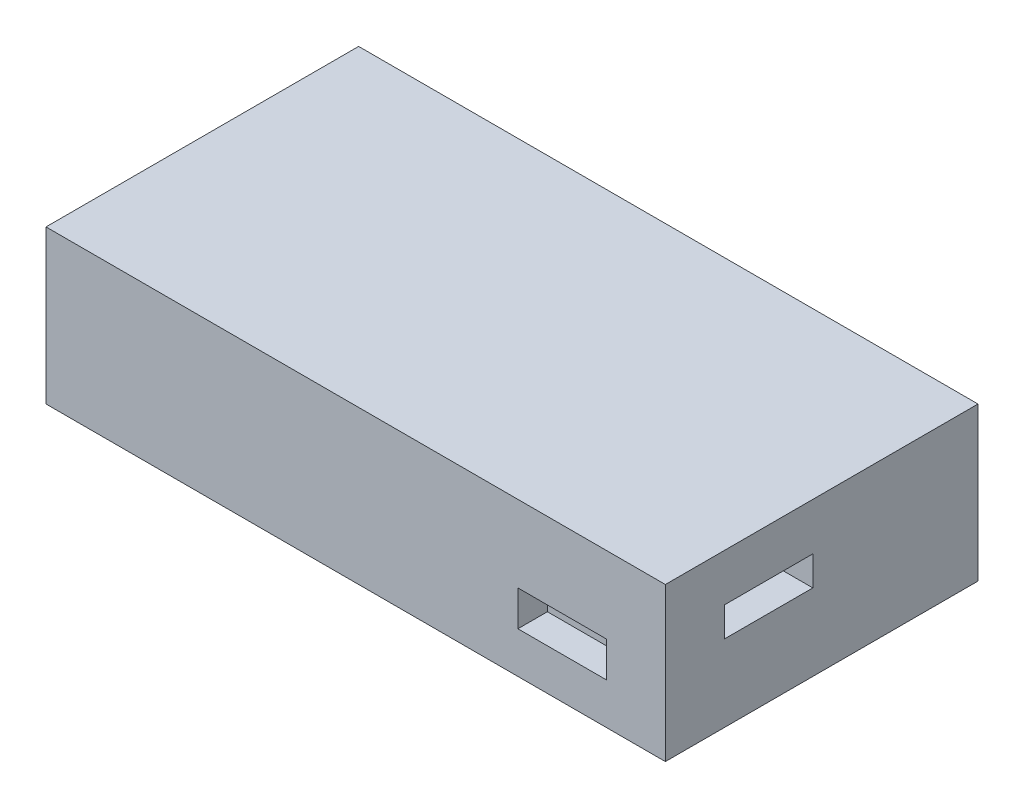
from build123d import *

# Parameters (mm, degrees)
SKETCH2_W           = 105
SKETCH2_H           = 53
BOSS_EXTRUDE1_DEPTH = 26
SKETCH3_W           = 15
SKETCH3_H           = 6
CUT_EXTRUDE1_DEPTH  = 5
SKETCH4_W           = 15
SKETCH4_H           = 5
CUT_EXTRUDE2_DEPTH  = 10


with BuildPart() as part:
    # Sketch2 → Boss-Extrude1 (new body)
    with BuildSketch(Plane(origin=(0, 0, 0), x_dir=(1, 0, 0), z_dir=(0, 1, 0))):
        with Locations((52.5, 26.5)):
            Rectangle(SKETCH2_W, SKETCH2_H)
    extrude(amount=BOSS_EXTRUDE1_DEPTH)

    # Sketch3 → Cut-Extrude1 (cut)
    with BuildSketch(Plane.XY):
        with Locations((87.5, 10)):
            Rectangle(SKETCH3_W, SKETCH3_H)
    extrude(amount=-CUT_EXTRUDE1_DEPTH, mode=Mode.SUBTRACT)

    # Sketch4 → Cut-Extrude2 (cut)
    with BuildSketch(Plane(origin=(105, 0, 0), x_dir=(0, 0, -1), z_dir=(1, 0, 0))):
        with Locations((17.5, 15.5)):
            Rectangle(SKETCH4_W, SKETCH4_H)
    extrude(amount=-CUT_EXTRUDE2_DEPTH, mode=Mode.SUBTRACT)


solid = part.part
